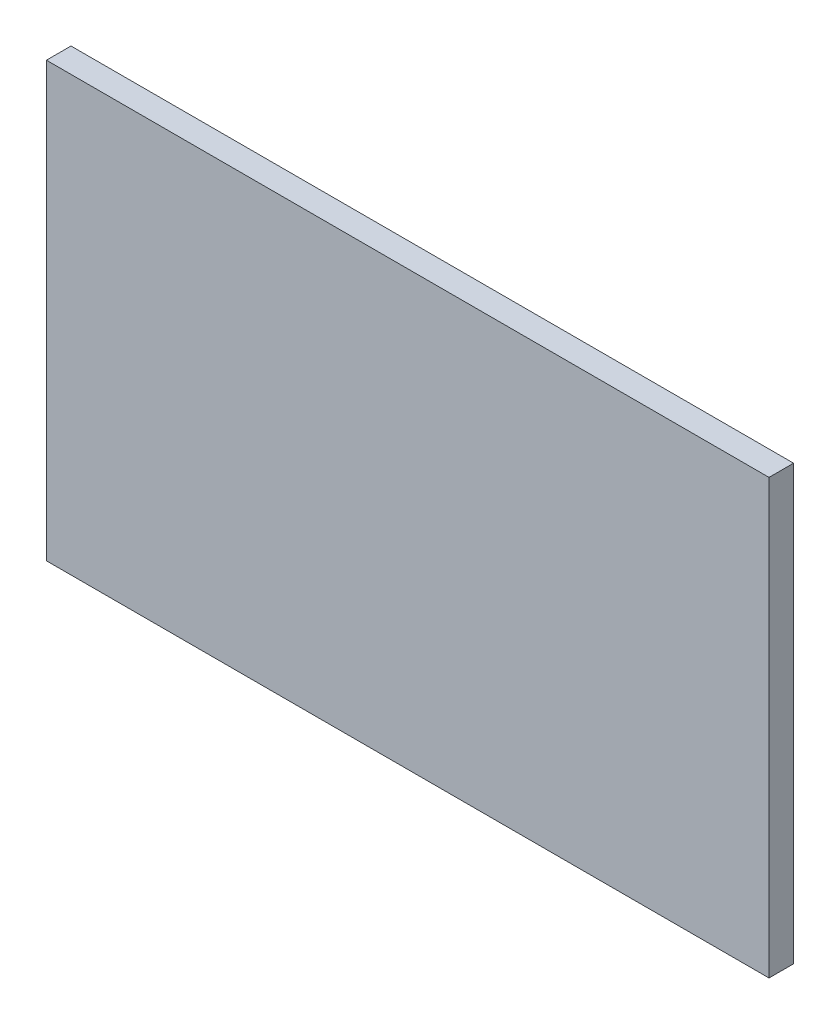
from build123d import *

# Parameters (mm, degrees)
SKETCH1_W           = 1000
SKETCH1_H           = 600
BOSS_EXTRUDE1_DEPTH = 34


with BuildPart() as part:
    # Sketch1 → Boss-Extrude1 (new body)
    with BuildSketch(Plane.XY):
        Rectangle(SKETCH1_W, SKETCH1_H)
    extrude(amount=BOSS_EXTRUDE1_DEPTH)


solid = part.part
